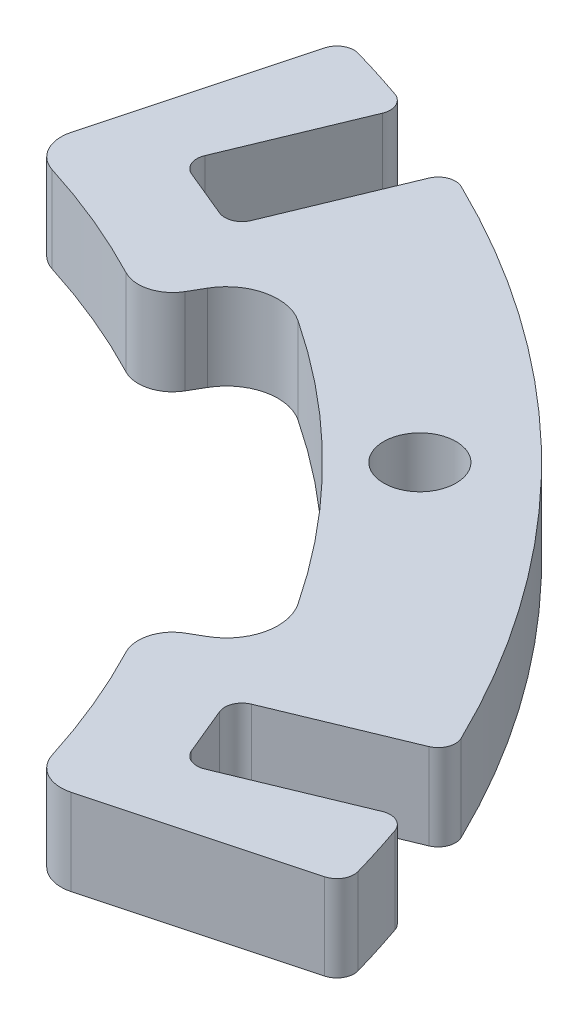
from build123d import *

# Parameters (mm, degrees)
SKETCH1_R                       = 60
SKETCH1_R_2                     = 45
BOSS_EXTRUDE1_DEPTH             = 5
CUT_EXTRUDE1_DEPTH              = 6
CIRPATTERN1_COUNT               = 8
SKETCH3_R                       = 2.1
CUT_EXTRUDE2_DEPTH              = 6
CIRPATTERN2_COUNT               = 4
SKIZZE1_OUTSIDE_W               = 155.956
SKIZZE1_OUTSIDE_H               = 155.956
SCHNITT_LINEAR_AUSTRAGEN1_DEPTH = 6
VERRUNDUNG1_R                   = 1
SCHNITT_LINEAR_AUSTRAGEN2_DEPTH = 6
VERRUNDUNG2_R                   = 1
KREISMUSTER1_COUNT              = 2
KREISMUSTER1_ANGLE              = 45
VERRUNDUNG2_OF_KREISMUSTER1_R   = 1


with BuildPart() as part:
    # Sketch1 → Boss-Extrude1 (new body)
    with BuildSketch(Plane(origin=(0, 0, 0), x_dir=(1, 0, 0), z_dir=(0, 1, 0))):
        Circle(SKETCH1_R)
        Circle(SKETCH1_R_2, mode=Mode.SUBTRACT)
    extrude(amount=BOSS_EXTRUDE1_DEPTH)

    # Sketch2 → Cut-Extrude1 (cut, through all)
    with BuildSketch(Plane(origin=(0, 5, 0), x_dir=(1, 0, 0), z_dir=(0, 1, 0))):
        with BuildLine():
            Line((12.399026137, 46.273795509), (12.153476553, 45.357391985))
            ThreePointArc((12.153476553, 45.357391985), (12.332388249, 43.876840862), (13.485952537, 42.931679261))
            Line((13.485952537, 42.931679261), (-13.485952537, 42.931679261))
            ThreePointArc((-13.485952537, 42.931679261), (-12.332388249, 43.876840862), (-12.153476553, 45.357391985))
            Line((-12.153476553, 45.357391985), (-12.399026137, 46.273795509))
            ThreePointArc((-12.399026137, 46.273795509), (-12.051156799, 48.63074892), (-10.0950767, 49.990893435))
            ThreePointArc((-10.0950767, 49.990893435), (0, 51), (10.0950767, 49.990893435))
            ThreePointArc((10.0950767, 49.990893435), (12.051156799, 48.63074892), (12.399026137, 46.273795509))
        make_face()
    cut_extrude1 = extrude(amount=-CUT_EXTRUDE1_DEPTH, mode=Mode.SUBTRACT)

    # CirPattern1: Cut-Extrude1 ×8 about axis
    cirpattern1_axis = Axis((0, 0, 0), (0, 1, 0))
    for i in range(1, CIRPATTERN1_COUNT):
        add(cut_extrude1.rotate(cirpattern1_axis, i * 360 / CIRPATTERN1_COUNT), mode=Mode.SUBTRACT)

    # Sketch3 → Cut-Extrude2 (cut, through all)
    with BuildSketch(Plane(origin=(0, 5, 0), x_dir=(1, 0, 0), z_dir=(0, 1, 0))):
        with Locations((38.890872965, 38.890872965)):
            Circle(SKETCH3_R)
    cut_extrude2 = extrude(amount=-CUT_EXTRUDE2_DEPTH, mode=Mode.SUBTRACT)

    # CirPattern2: Cut-Extrude2 ×4 about axis
    cirpattern2_axis = Axis((0, 0, 0), (0, 1, 0))
    for i in range(1, CIRPATTERN2_COUNT):
        add(cut_extrude2.rotate(cirpattern2_axis, i * 360 / CIRPATTERN2_COUNT), mode=Mode.SUBTRACT)

    # Skizze1 outside → Schnitt-Linear austragen1 (cut, through all)
    with BuildSketch(Plane(origin=(0, 5, 0), x_dir=(1, 0, 0), z_dir=(0, 1, 0))):
        Rectangle(SKIZZE1_OUTSIDE_W, SKIZZE1_OUTSIDE_H)
        Polygon((0, 0), (24.798052275, 92.547591019), (92.547591019, 24.798052275), align=None, mode=Mode.SUBTRACT)
    extrude(amount=-SCHNITT_LINEAR_AUSTRAGEN1_DEPTH, mode=Mode.SUBTRACT)

    # Verrundung1
    verrundung1_edges = [part.edges().sort_by_distance(p)[0] for p in [
        (57.955549577, 2.5, -15.529142706),
        (15.529142706, 2.5, -57.955549577),
    ]]
    fillet(verrundung1_edges, radius=VERRUNDUNG1_R)

    # Skizze2 → Schnitt-Linear austragen2 (cut, through all)
    with BuildSketch(Plane(origin=(0, 5, 0), x_dir=(1, 0, 0), z_dir=(0, 1, 0))):
        Polygon((16.824472787, 47.150685206), (21.44387045, 45.237268045), (25.270704773, 54.47606337), (20.651307111, 56.389480532), align=None)
    schnitt_linear_austragen2 = extrude(amount=-SCHNITT_LINEAR_AUSTRAGEN2_DEPTH, mode=Mode.SUBTRACT)

    # Verrundung2
    verrundung2_edges = [part.edges().sort_by_distance(p)[0] for p in [
        (20.631367024, 2.5, -56.341340903),
        (25.250764686, 2.5, -54.427923741),
        (16.824472787, 2.5, -47.150685206),
        (21.44387045, 2.5, -45.237268045),
    ]]
    fillet(verrundung2_edges, radius=VERRUNDUNG2_R)

    # Kreismuster1: Schnitt-Linear austragen2 ×2 about axis
    kreismuster1_axis = Axis((0, 0, 0), (0, -1, 0))
    for i in range(1, KREISMUSTER1_COUNT):
        add(schnitt_linear_austragen2.rotate(kreismuster1_axis, i * KREISMUSTER1_ANGLE / (KREISMUSTER1_COUNT - 1)), mode=Mode.SUBTRACT)

    # Verrundung2 of Kreismuster1
    verrundung2_of_kreismuster1_edges = [part.edges().sort_by_distance(p)[0] for p in [
        (54.427923741, 2.5, -25.250764686),
        (56.341340903, 2.5, -20.631367024),
        (45.237268045, 2.5, -21.44387045),
        (47.150685206, 2.5, -16.824472787),
    ]]
    fillet(verrundung2_of_kreismuster1_edges, radius=VERRUNDUNG2_OF_KREISMUSTER1_R)


solid = part.part
